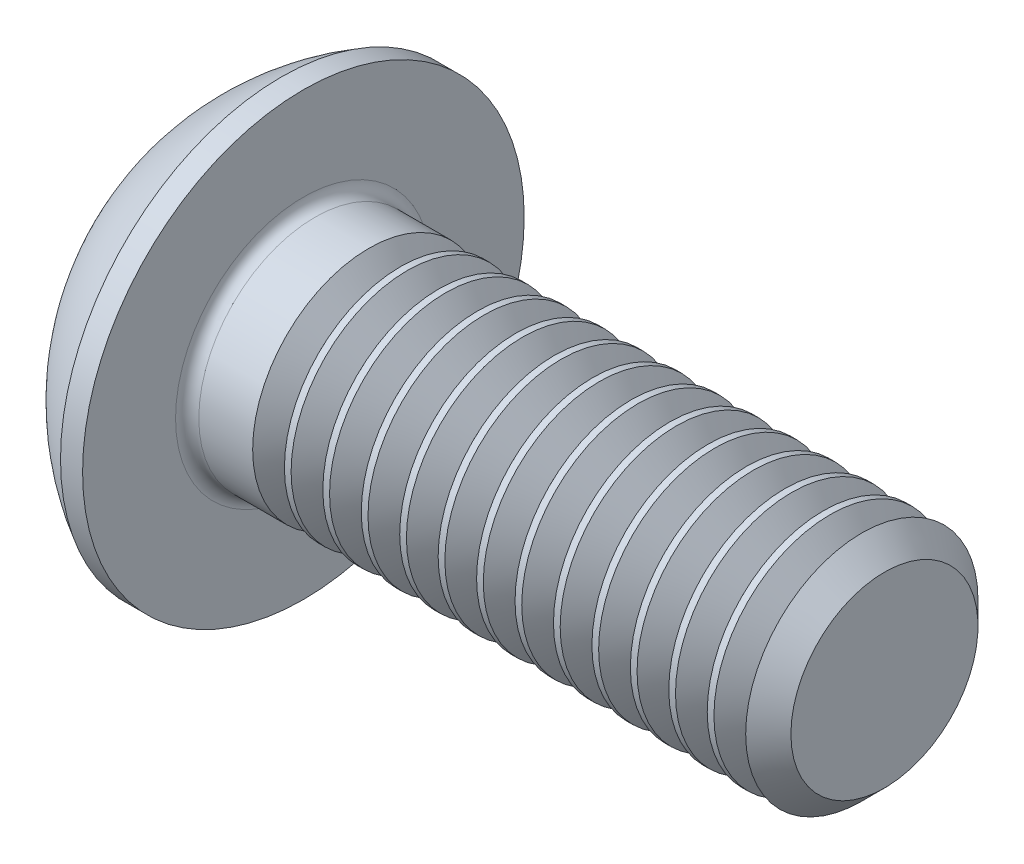
from build123d import *

# Parameters (mm, degrees)
FILLET1_R       = 0.2
HEX_2_DEPTH     = 1.3
THDSCHPAT_COUNT = 13
THDSCHPAT_PITCH = 0.661538462


with BuildPart() as part:
    # BodySke → BaseBody (revolve)
    with BuildSketch(Plane.XY):
        with BuildLine():
            Line((12.2, 0), (12.2, 1.61))
            Line((12.2, 1.61), (11.81, 2))
            Line((11.81, 2), (2.2, 2))
            Line((2.2, 2), (2.2, 3.8))
            Line((2.2, 3.8), (1.82, 3.8))
            ThreePointArc((1.82, 3.8), (0.762013659, 2.991755338), (0, 1.9))
            Line((0, 1.9), (0, 0))
            Line((0, 0), (12.2, 0))
        make_face()
    revolve(axis=Axis((0, 0, 0), (1, 0, 0)))

    # Fillet1
    fillet1_edges = [part.edges().sort_by_distance(p)[0] for p in [
        (2.2, -2, 0),
    ]]
    fillet(fillet1_edges, radius=FILLET1_R)

    # Sketch2 → PreBroach (revolve, cut)
    with BuildSketch(Plane.XY):
        Polygon((0, 1.25), (1.3, 1.25), (2.021687836, 0), (0, 0), align=None)
    revolve(axis=Axis((0, 0, 0), (1, 0, 0)), mode=Mode.SUBTRACT)

    # Sketch3 → Hex 2 (cut)
    with BuildSketch(Plane(origin=(0, 0, 0), x_dir=(0, 0, -1), z_dir=(1, 0, 0))):
        Polygon((-1.25, -0.721687836), (-1.25, 0.721687836), (0, 1.443375673), (1.25, 0.721687836), (1.25, -0.721687836), (0, -1.443375673), align=None)
    extrude(amount=HEX_2_DEPTH, mode=Mode.SUBTRACT)

    # ThdSchSke → ThreadSchematic (revolve, cut)
    with BuildSketch(Plane.XY):
        Polygon((3.6, -1.61), (3.32691906, -2), (3.32691906, -2.5), (3.87308094, -2.5), (3.87308094, -2), align=None)
    threadschematic = revolve(axis=Axis((-3.175, 0, 0), (1, 0, 0)), mode=Mode.SUBTRACT)

    # ThdSchPat: ThreadSchematic ×13
    with Locations(*[(i * THDSCHPAT_PITCH, 0, 0) for i in range(1, THDSCHPAT_COUNT)]):
        add(threadschematic, mode=Mode.SUBTRACT)


solid = part.part
